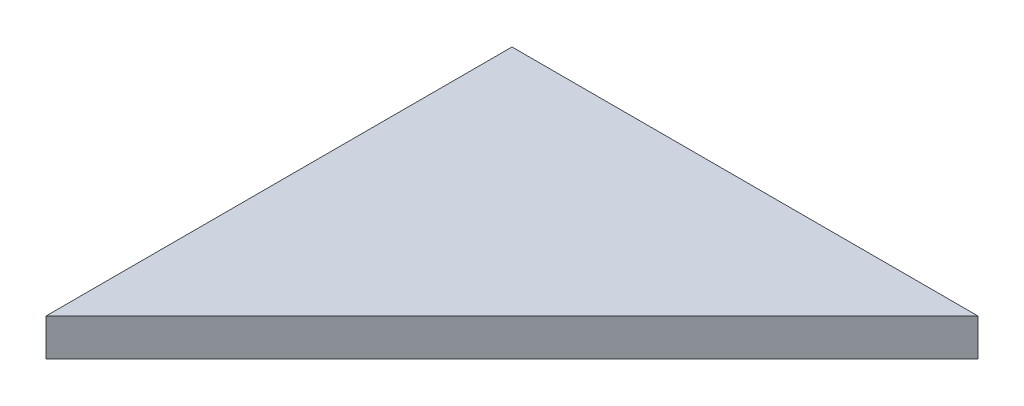
from build123d import *

# Parameters (mm, degrees)
EXTRUDE_A_DEPTH = 6.4


with BuildPart() as part:
    # puzzle plan → Extrude A (new body)
    with BuildSketch(Plane(origin=(0, 0, 0), x_dir=(1, 0, 0), z_dir=(0, 1, 0))):
        Polygon((0, 100), (0, 20), (28, 48), (52, 72), (80, 100), align=None)
    extrude(amount=EXTRUDE_A_DEPTH)


solid = part.part
